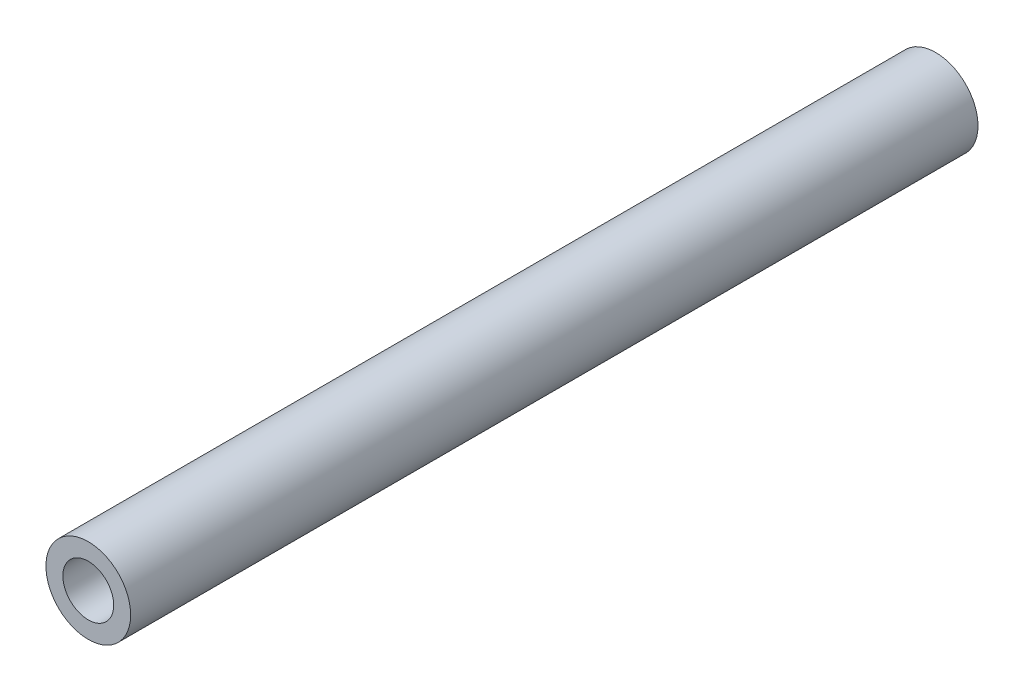
from build123d import *

# Parameters (mm, degrees)
SKETCH1_R           = 250
SKETCH1_R_2         = 150
BOSS_EXTRUDE1_DEPTH = 5000


with BuildPart() as part:
    # Sketch1 → Boss-Extrude1 (new body)
    with BuildSketch(Plane.XY):
        Circle(SKETCH1_R)
        Circle(SKETCH1_R_2, mode=Mode.SUBTRACT)
    extrude(amount=BOSS_EXTRUDE1_DEPTH)


solid = part.part
